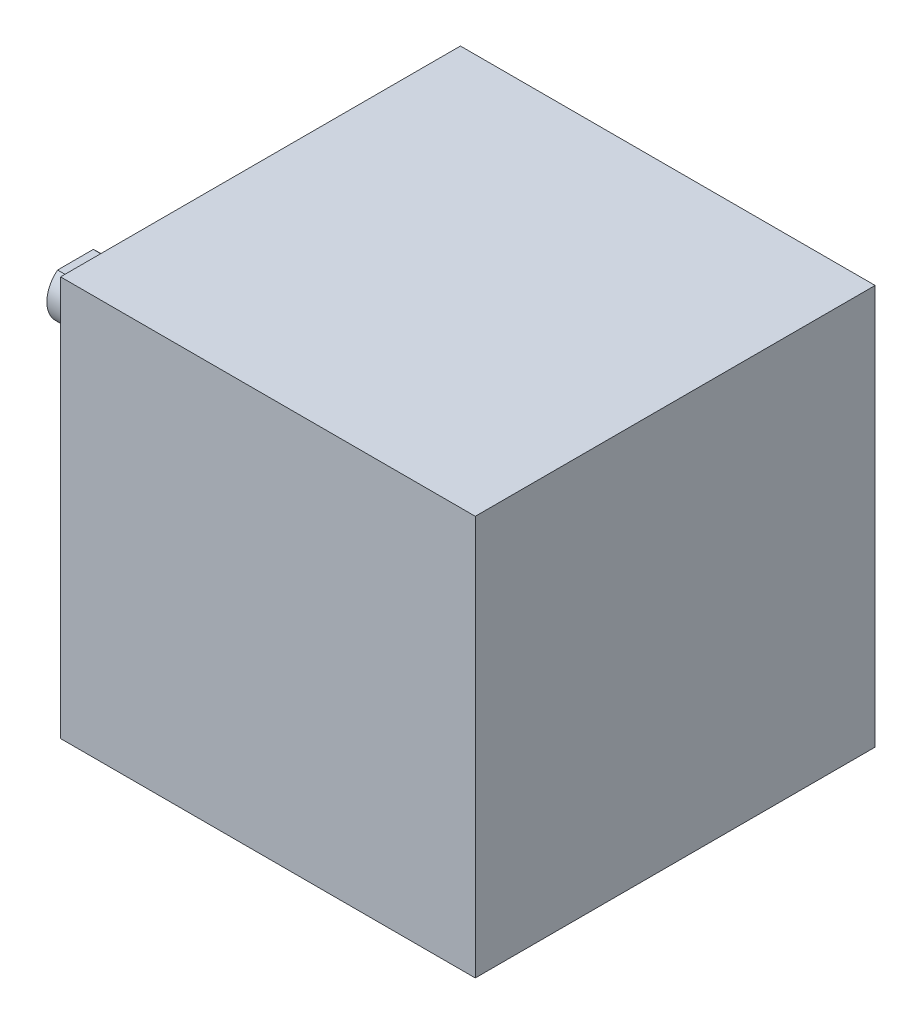
from build123d import *

# Parameters (mm, degrees)
SKETCH1_W           = 35
SKETCH1_H           = 35
BOSS_EXTRUDE1_DEPTH = 36.3
SKETCH2_R           = 11
BOSS_EXTRUDE2_DEPTH = 2
BOSS_EXTRUDE4_DEPTH = 14.2


with BuildPart() as part:
    # Sketch1 → Boss-Extrude1 (new body)
    with BuildSketch(Plane(origin=(0, 0, 0), x_dir=(0, 0, -1), z_dir=(1, 0, 0))):
        with Locations((-17.5, -17.5)):
            Rectangle(SKETCH1_W, SKETCH1_H)
    extrude(amount=BOSS_EXTRUDE1_DEPTH)

    # Sketch2 → Boss-Extrude2 (add)
    with BuildSketch(Plane.ZY):
        with Locations((17.5, -17.5)):
            Circle(SKETCH2_R)
    extrude(amount=BOSS_EXTRUDE2_DEPTH)

    # Sketch3 → Boss-Extrude4 (add)
    with BuildSketch(Plane.ZY.offset(2)):
        with BuildLine():
            Line((17.5, -15.55), (19.064448785, -15.55))
            ThreePointArc((19.064448785, -15.55), (17.5, -20), (15.935551215, -15.55))
            Line((15.935551215, -15.55), (17.5, -15.55))
        make_face()
    extrude(amount=BOSS_EXTRUDE4_DEPTH)


solid = part.part
